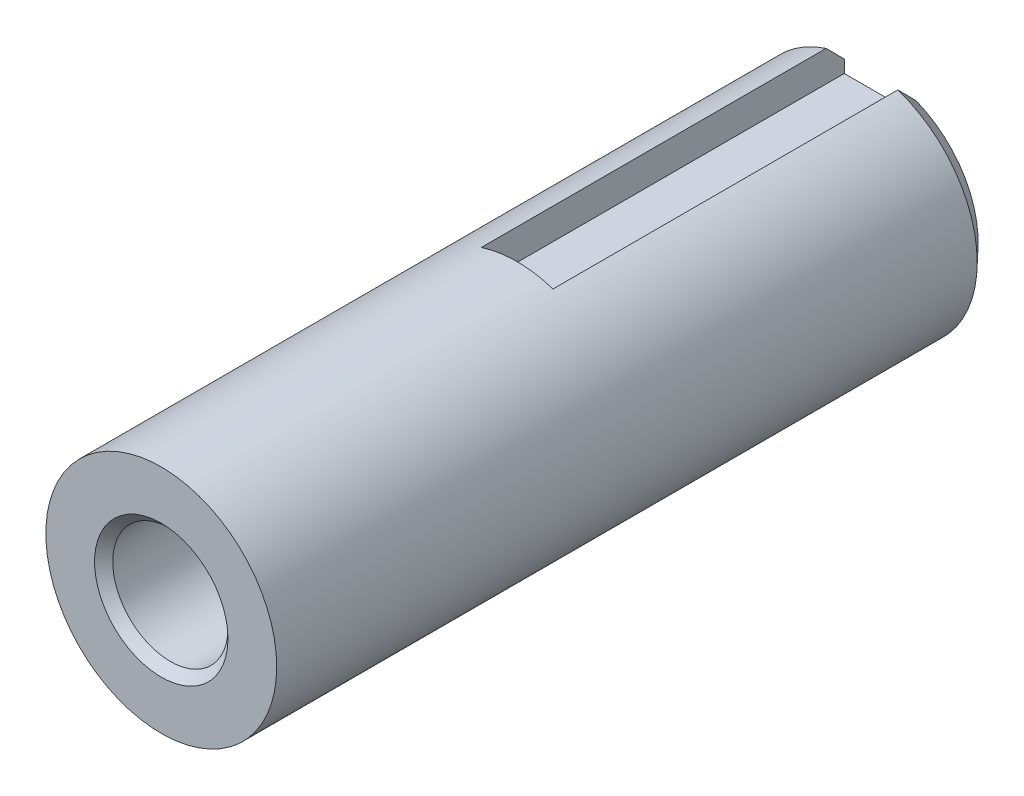
from build123d import *

# Parameters (mm, degrees)
CROQUIS3_R              = 6.36
SALIENTE_EXTRUIR2_DEPTH = 39.6
CROQUIS4_R              = 3.175
CORTAR_EXTRUIR1_DEPTH   = 19.3
CROQUIS6_W              = 3.95
CROQUIS6_H              = 2.393963958
CORTAR_EXTRUIR3_DEPTH   = 20
CHAFL_N1_SIZE           = 0.95
CHAFL_N1_SIZE2          = 1
CHAFL_N2_SIZE           = 0.5


with BuildPart() as part:
    # Croquis3 → Saliente-Extruir2 (new body)
    with BuildSketch(Plane.XY):
        Circle(CROQUIS3_R)
    extrude(amount=-SALIENTE_EXTRUIR2_DEPTH)

    # Croquis4 → Cortar-Extruir1 (cut)
    with BuildSketch(Plane.XY):
        Circle(CROQUIS4_R)
    extrude(amount=-CORTAR_EXTRUIR1_DEPTH, mode=Mode.SUBTRACT)

    # Croquis6 → Cortar-Extruir3 (cut)
    with BuildSketch(Plane(origin=(0, 0, -39.6), x_dir=(-1, 0, 0), z_dir=(0, 0, -1))):
        with Locations((-0.01, 5.546981979)):
            Rectangle(CROQUIS6_W, CROQUIS6_H)
    extrude(amount=-CORTAR_EXTRUIR3_DEPTH, mode=Mode.SUBTRACT)

    # Chaflán1
    chafl_n1_edges = [part.edges().sort_by_distance(p)[0] for p in [
        (-3.738462251, -5.145240519, -39.6),
    ]]
    chafl_n1_side = [part.faces().sort_by_distance(p)[0] for p in [
        (-0.000560241, -0.334162106, -39.6),
    ]]
    chamfer(chafl_n1_edges, length=CHAFL_N1_SIZE, length2=CHAFL_N1_SIZE2, reference=chafl_n1_side[0])

    # Chaflán2
    chafl_n2_edges = [part.edges().sort_by_distance(p)[0] for p in [
        (-3.175, 0, 0),
    ]]
    chamfer(chafl_n2_edges, length=CHAFL_N2_SIZE)


solid = part.part
